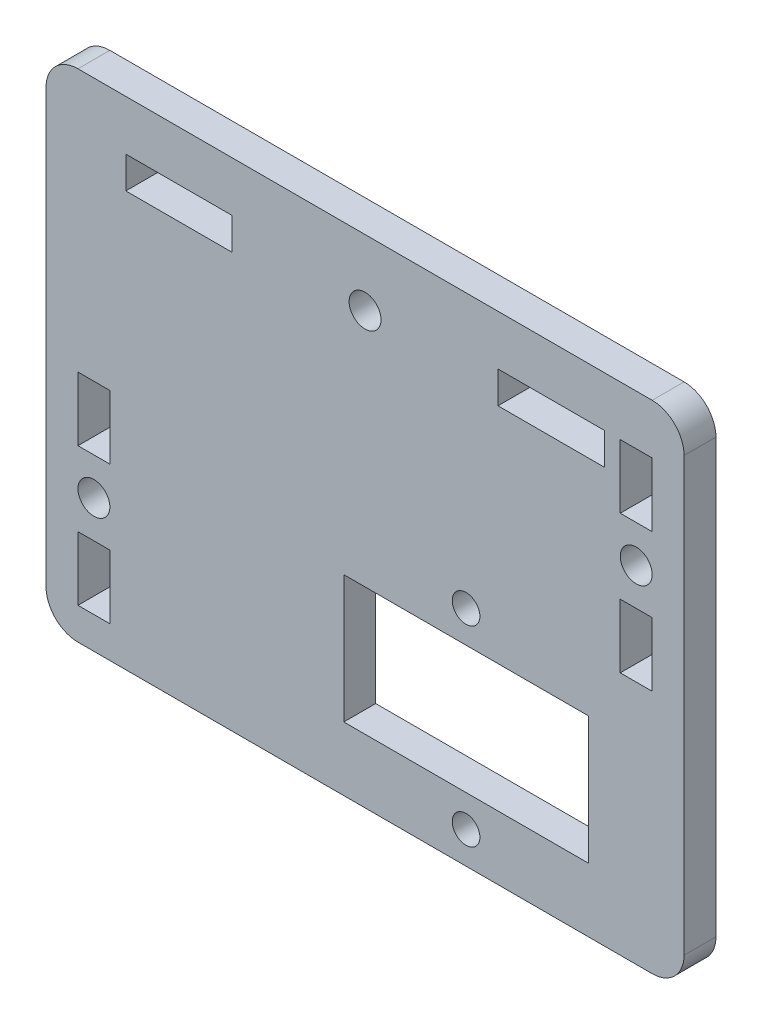
from build123d import *

# Parameters (mm, degrees)
MODEL_R             = 1.500000002
MODEL_R_2           = 1.300000002
MODEL_R_3           = 1.500000003
MODEL_W             = 3
MODEL_H             = 6
MODEL_W_2           = 10
MODEL_H_2           = 3
MODEL_W_3           = 23
MODEL_H_3           = 12
BOSS_EXTRUDE1_DEPTH = 3


with BuildPart() as part:
    # Model → Boss-Extrude1 (new body)
    with BuildSketch(Plane.XY):
        with BuildLine():
            Line((28.47306014, 22.66800001), (28.473164499, 63.3680236))
            ThreePointArc((28.473164499, 63.3680236), (29.351812484, 65.489297995), (31.473064499, 66.36800001))
            Line((31.473064499, 66.36800001), (85.473064499, 66.36800001))
            ThreePointArc((85.473064499, 66.36800001), (87.594368353, 65.489496156), (88.473064511, 63.368271953))
            Line((88.473064511, 63.368271953), (88.473064511, 22.66800001))
            ThreePointArc((88.473064511, 22.66800001), (87.594512967, 20.546548464), (85.47306014, 19.66800001))
            Line((85.47306014, 19.66800001), (31.47306014, 19.66800001))
            ThreePointArc((31.47306014, 19.66800001), (29.351710139, 20.54665001), (28.47306014, 22.66800001))
        make_face()
        with Locations((32.973060142, 32.168000012)):
            Circle(MODEL_R, mode=Mode.SUBTRACT)
        with Locations((58.473060142, 60.168000012)):
            Circle(MODEL_R, mode=Mode.SUBTRACT)
        with Locations((67.973060142, 22.668000012)):
            Circle(MODEL_R_2, mode=Mode.SUBTRACT)
        with Locations((67.973060142, 40.668000012)):
            Circle(MODEL_R_2, mode=Mode.SUBTRACT)
        with Locations((83.97306014, 52.16800001)):
            Circle(MODEL_R_3, mode=Mode.SUBTRACT)
        with Locations((32.97306014, 38.66800001)):
            Rectangle(MODEL_W, MODEL_H, mode=Mode.SUBTRACT)
        with Locations((40.97306014, 60.16800001)):
            Rectangle(MODEL_W_2, MODEL_H_2, mode=Mode.SUBTRACT)
        with Locations((32.97306014, 25.66800001)):
            Rectangle(MODEL_W, MODEL_H, mode=Mode.SUBTRACT)
        with Locations((75.97306014, 60.16800001)):
            Rectangle(MODEL_W_2, MODEL_H_2, mode=Mode.SUBTRACT)
        with Locations((83.97306014, 58.66800001)):
            Rectangle(MODEL_W, MODEL_H, mode=Mode.SUBTRACT)
        with Locations((83.97306014, 45.66800001)):
            Rectangle(MODEL_W, MODEL_H, mode=Mode.SUBTRACT)
        with Locations((67.97306014, 31.66800001)):
            Rectangle(MODEL_W_3, MODEL_H_3, mode=Mode.SUBTRACT)
    extrude(amount=BOSS_EXTRUDE1_DEPTH)


solid = part.part
